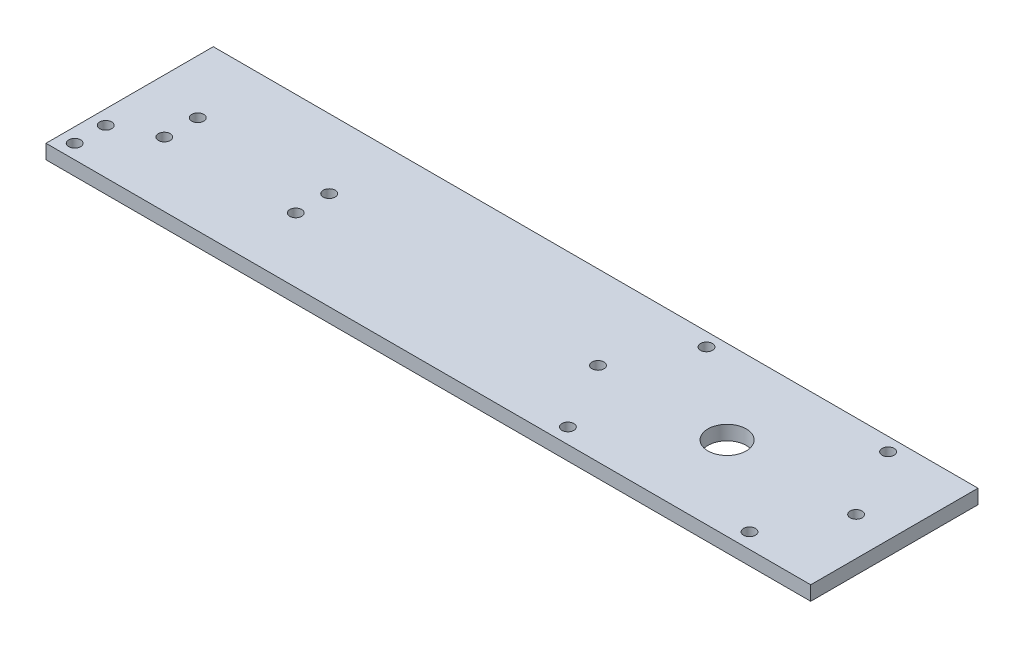
from build123d import *

# Parameters (mm, degrees)
SKETCH1_W           = 160
SKETCH1_H           = 35
SKETCH1_R           = 1.25
SKETCH1_R_2         = 4
BOSS_EXTRUDE1_DEPTH = 3
SKETCH3_R           = 1.25
CUT_EXTRUDE7_DEPTH  = 10


with BuildPart() as part:
    # Sketch1 → Boss-Extrude1 (new body)
    with BuildSketch(Plane(origin=(0, 0, 0), x_dir=(1, 0, 0), z_dir=(0, 1, 0))):
        with Locations((-20, 5)):
            Rectangle(SKETCH1_W, SKETCH1_H)
        with Locations((-97, -9.5)):
            Circle(SKETCH1_R, mode=Mode.SUBTRACT)
        with Locations((-97, -3)):
            Circle(SKETCH1_R, mode=Mode.SUBTRACT)
        with Locations((-88.75, 1)):
            Circle(SKETCH1_R, mode=Mode.SUBTRACT)
        with Locations((-61.25, 1)):
            Circle(SKETCH1_R, mode=Mode.SUBTRACT)
        with Locations((-88.75, 8)):
            Circle(SKETCH1_R, mode=Mode.SUBTRACT)
        with Locations((-61.25, 8)):
            Circle(SKETCH1_R, mode=Mode.SUBTRACT)
        with Locations((-2, 5)):
            Circle(SKETCH1_R, mode=Mode.SUBTRACT)
        with Locations((25, 5)):
            Circle(SKETCH1_R_2, mode=Mode.SUBTRACT)
        with Locations((52, 5)):
            Circle(SKETCH1_R, mode=Mode.SUBTRACT)
    extrude(amount=BOSS_EXTRUDE1_DEPTH)

    # Sketch3 → Cut-Extrude7 (cut)
    with BuildSketch(Plane(origin=(0, 3, 0), x_dir=(-1, 0, 0), z_dir=(0, -1, 0))):
        with Locations((-44, -9.307637977)):
            Circle(SKETCH3_R)
        with Locations((-6, -9.307637977)):
            Circle(SKETCH3_R)
        with Locations((-6, 19.692362023)):
            Circle(SKETCH3_R)
        with Locations((-44, 19.692362023)):
            Circle(SKETCH3_R)
    extrude(amount=CUT_EXTRUDE7_DEPTH, mode=Mode.SUBTRACT)


solid = part.part
